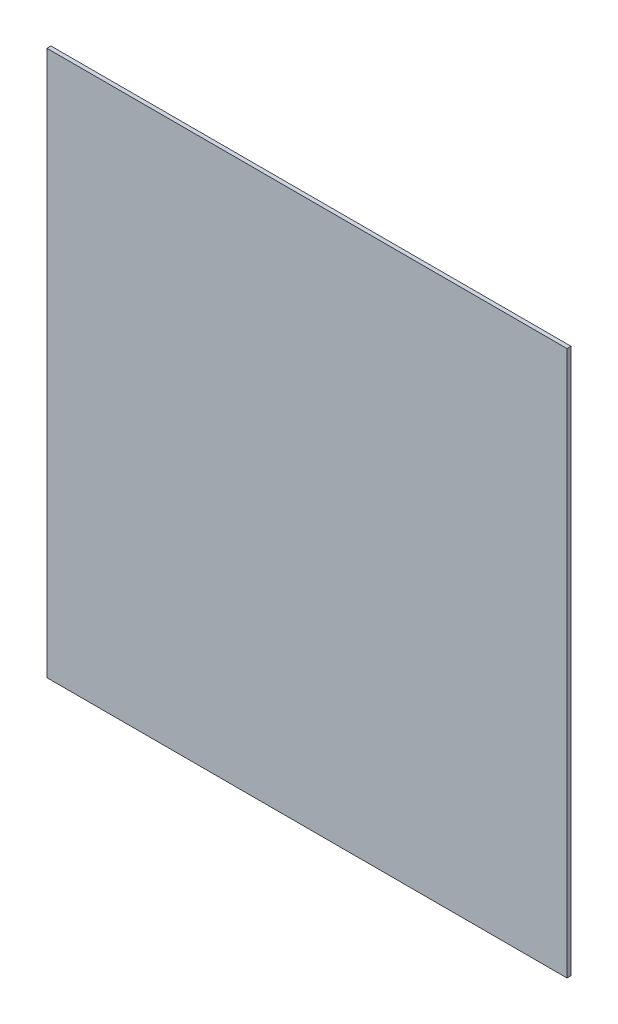
from build123d import *

# Parameters (mm, degrees)
SKETCH1_W           = 16.415
SKETCH1_H           = 17.20875
BOSS_EXTRUDE1_DEPTH = 0.127


with BuildPart() as part:
    # Sketch1 → Boss-Extrude1 (new body)
    with BuildSketch(Plane.XY):
        with Locations((-73.66, -84.3122297)):
            Rectangle(SKETCH1_W, SKETCH1_H)
    extrude(amount=BOSS_EXTRUDE1_DEPTH)


solid = part.part
